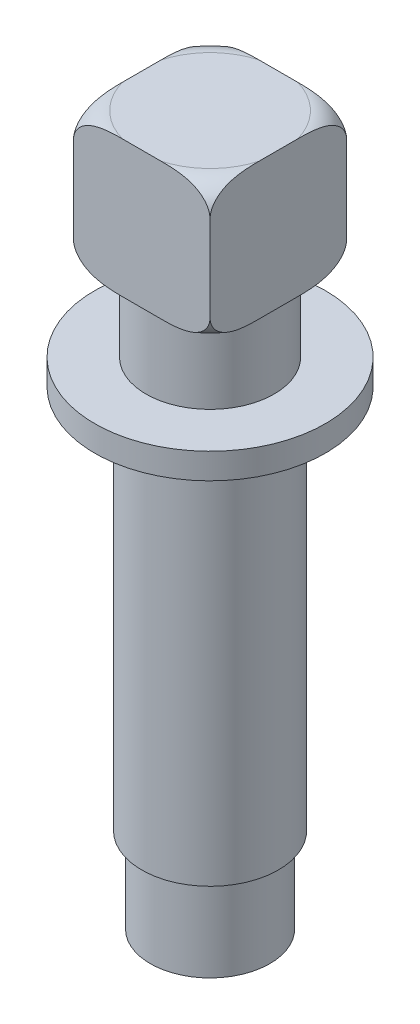
from build123d import *

# Parameters (mm, degrees)
SKETCH2_W           = 16
SKETCH2_H           = 16
BOSS_EXTRUDE1_DEPTH = 16


with BuildPart() as part:
    # Sketch1 → Revolve1 (revolve)
    with BuildSketch(Plane.XY):
        Polygon((0, 0), (7, 0), (7, 10), (8, 10), (8, 55), (13.5, 55), (13.5, 58), (7.5, 58), (7.5, 67), (0, 67), align=None)
    revolve(axis=Axis((0, 0, 0), (0, 1, 0)))

    # Sketch2 → Boss-Extrude1 (add)
    with BuildSketch(Plane(origin=(0, 67, 0), x_dir=(1, 0, 0), z_dir=(0, 1, 0))):
        Rectangle(SKETCH2_W, SKETCH2_H)
    extrude(amount=BOSS_EXTRUDE1_DEPTH)

    # Sketch4 → Cut-Revolve1 (revolve, cut)
    with BuildSketch(Plane(origin=(0, 0, 0), x_dir=(0.707106781, 0, -0.707106781), z_dir=(0.707106781, 0, 0.707106781))):
        with BuildLine():
            Line((11.313708499, 83), (8.313708499, 83))
            ThreePointArc((8.313708499, 83), (10.435028843, 82.121320344), (11.313708499, 80))
            Line((11.313708499, 80), (11.313708499, 83))
        make_face()
        with BuildLine():
            Line((11.313708499, 67), (8.313708499, 67))
            ThreePointArc((8.313708499, 67), (10.435028843, 67.878679656), (11.313708499, 70))
            Line((11.313708499, 70), (11.313708499, 67))
        make_face()
    revolve(axis=Axis((0, 66.528771151, 0), (0, 1, 0)), mode=Mode.SUBTRACT)


solid = part.part
